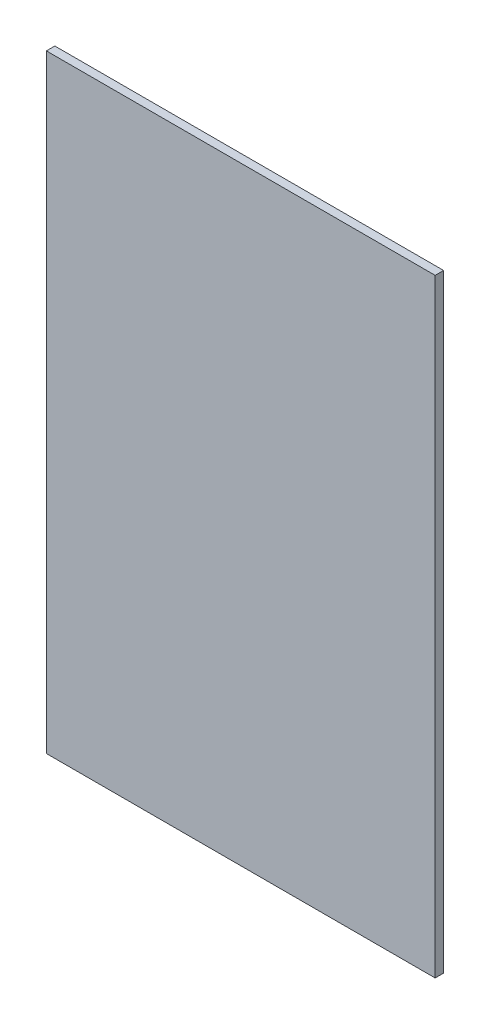
from build123d import *

# Parameters (mm, degrees)
SKETCH1_W           = 584.2
SKETCH1_H           = 914.4
BOSS_EXTRUDE1_DEPTH = 12.7


with BuildPart() as part:
    # Sketch1 → Boss-Extrude1 (new body)
    with BuildSketch(Plane.XY):
        Rectangle(SKETCH1_W, SKETCH1_H)
    extrude(amount=BOSS_EXTRUDE1_DEPTH)


solid = part.part
